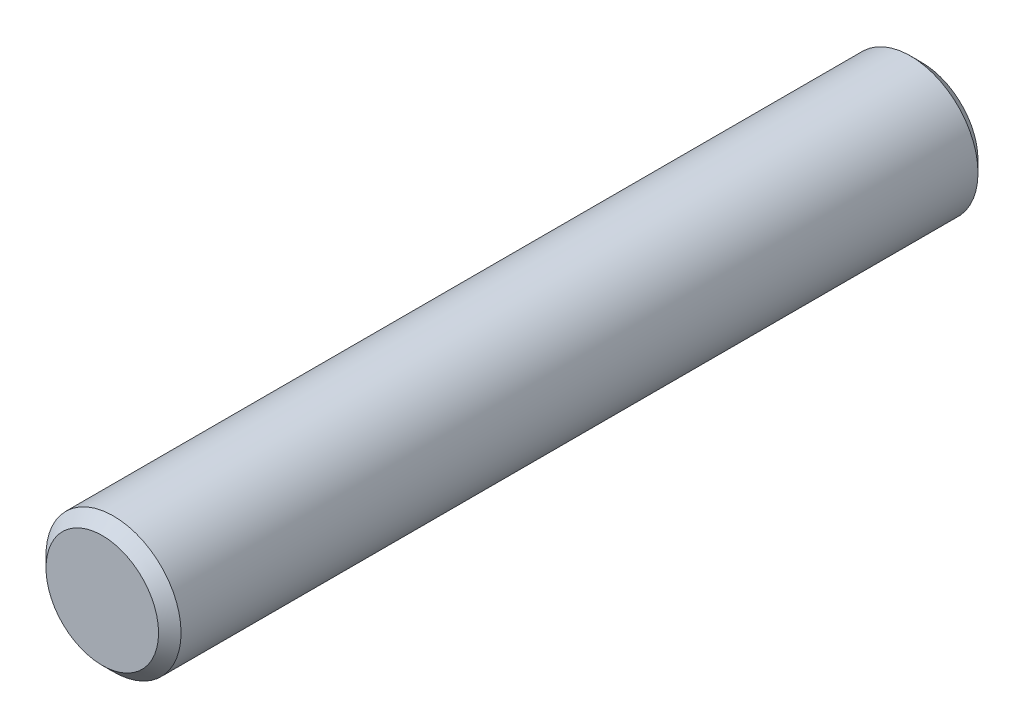
from build123d import *

# Parameters (mm, degrees)
SKETCH1_R           = 3
BOSS_EXTRUDE1_DEPTH = 36.40099384
CHAMFER1_SIZE       = 0.5


with BuildPart() as part:
    # Sketch1 → Boss-Extrude1 (new body)
    with BuildSketch(Plane.XY):
        Circle(SKETCH1_R)
    extrude(amount=BOSS_EXTRUDE1_DEPTH)

    # Chamfer1
    chamfer1_edges = [part.edges().sort_by_distance(p)[0] for p in [
        (-3, 0, 0),
        (-3, 0, 36.40099384),
    ]]
    chamfer(chamfer1_edges, length=CHAMFER1_SIZE)


solid = part.part
